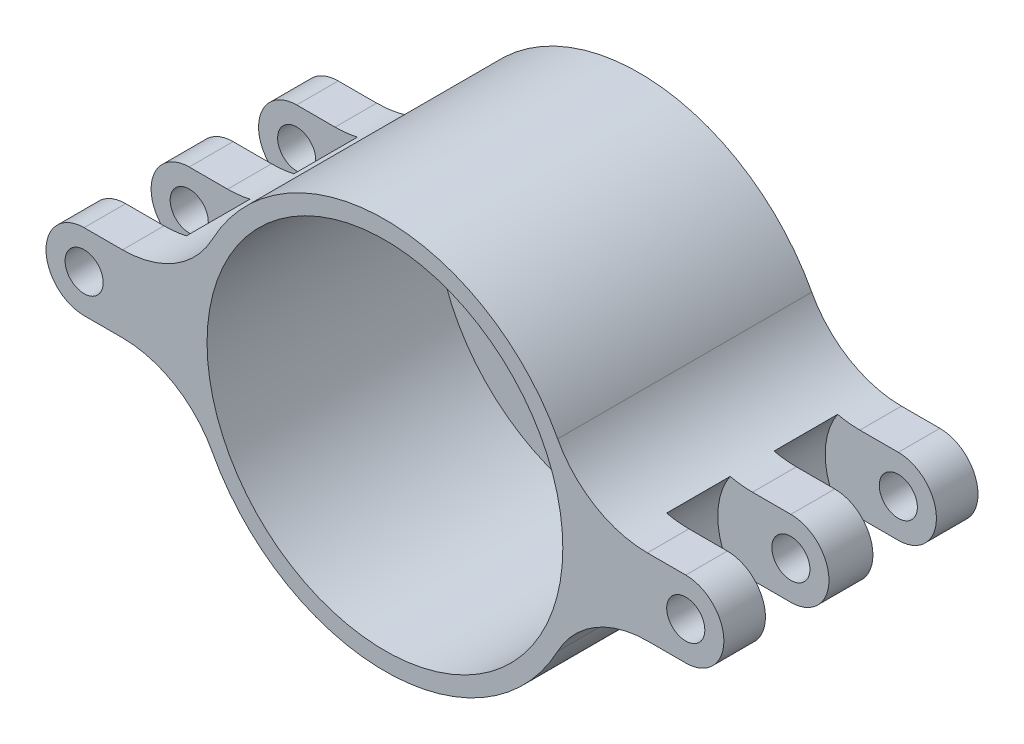
from build123d import *

# Parameters (mm, degrees)
SKETCH1_R                 = 15.4
BOSS_EXTRUDE1_DEPTH       = 20
BOSS_EXTRUDE2_DEPTH       = 20
FILLET4_R                 = 8
CIRPATTERN11_COUNT        = 2
FILLET4_OF_CIRPATTERN11_R = 8
SKETCH4_R                 = 14
CUT_EXTRUDE3_DEPTH        = 18
SKETCH5_R                 = 5
CUT_EXTRUDE4_DEPTH        = 19
CUT_EXTRUDE4_DEPTH_BACK   = 3
CUT_EXTRUDE5_START        = -3
SKETCH7_R                 = 3
CUT_EXTRUDE5_DEPTH        = 22
CIRPATTERN12_COUNT        = 4
CUT_EXTRUDE1_START        = -21
SKETCH2_R                 = 1.5
CUT_EXTRUDE1_DEPTH        = 22
CIRPATTERN10_COUNT        = 2
SKETCH3_R                 = 5.75
CUT_EXTRUDE2_DEPTH        = 2.5
CIRPATTERN3_COUNT         = 2
MIRROR1_COPY_1_SKETCH_R   = 5.75
MIRROR1_COPY_1_DEPTH      = 2.5


with BuildPart() as part:
    # Sketch1 → Boss-Extrude1 (new body)
    with BuildSketch(Plane.XY):
        Circle(SKETCH1_R)
    extrude(amount=BOSS_EXTRUDE1_DEPTH)

    # Sketch6 → Boss-Extrude2 (add)
    with BuildSketch(Plane.XY.offset(20)):
        with BuildLine():
            Line((-23.675, 3), (-15.104966071, 3))
            ThreePointArc((-15.104966071, 3), (-15.4, 0), (-15.104966071, -3))
            Line((-15.104966071, -3), (-23.675, -3))
            ThreePointArc((-23.675, -3), (-26.675, 0), (-23.675, 3))
        make_face()
    boss_extrude2 = extrude(amount=-BOSS_EXTRUDE2_DEPTH)

    # Fillet4
    fillet4_edges = [part.edges().sort_by_distance(p)[0] for p in [
        (-15.104966071, 3, 10),
        (-15.104966071, -3, 10),
    ]]
    fillet(fillet4_edges, radius=FILLET4_R)

    # CirPattern11: Boss-Extrude2 ×2 about axis
    cirpattern11_axis = Axis((0, 0, 0), (0, 0, 1))
    for i in range(1, CIRPATTERN11_COUNT):
        add(boss_extrude2.rotate(cirpattern11_axis, i * 360 / CIRPATTERN11_COUNT))

    # Fillet4 of CirPattern11
    fillet4_of_cirpattern11_edges = [part.edges().sort_by_distance(p)[0] for p in [
        (15.104966071, -3, 10),
        (15.104966071, 3, 10),
    ]]
    fillet(fillet4_of_cirpattern11_edges, radius=FILLET4_OF_CIRPATTERN11_R)

    # Sketch4 → Cut-Extrude3 (cut)
    with BuildSketch(Plane.XY.offset(20)):
        Circle(SKETCH4_R)
    extrude(amount=-CUT_EXTRUDE3_DEPTH, mode=Mode.SUBTRACT)

    # Sketch5 → Cut-Extrude4 (cut, two sides)
    with BuildSketch(Plane.XY.offset(2)) as cut_extrude4_sk:
        Circle(SKETCH5_R)
    extrude(amount=CUT_EXTRUDE4_DEPTH, mode=Mode.SUBTRACT)
    extrude(cut_extrude4_sk.sketch, amount=-CUT_EXTRUDE4_DEPTH_BACK, mode=Mode.SUBTRACT)

    # Sketch7 → Cut-Extrude5 (cut)
    with BuildSketch(Plane.XY.offset(2).offset(CUT_EXTRUDE5_START)):
        with Locations((-8.4, 0)):
            Circle(SKETCH7_R)
    cut_extrude5 = extrude(amount=CUT_EXTRUDE5_DEPTH, mode=Mode.SUBTRACT)

    # CirPattern12: Cut-Extrude5 ×4 about axis
    cirpattern12_axis = Axis((0, 0, 0), (0, 0, 1))
    for i in range(1, CIRPATTERN12_COUNT):
        add(cut_extrude5.rotate(cirpattern12_axis, i * 360 / CIRPATTERN12_COUNT), mode=Mode.SUBTRACT)

    # Sketch2 → Cut-Extrude1 (cut)
    with BuildSketch(Plane.XY.offset(20).offset(CUT_EXTRUDE1_START)):
        with Locations((-23.675, 0)):
            Circle(SKETCH2_R)
    cut_extrude1 = extrude(amount=CUT_EXTRUDE1_DEPTH, mode=Mode.SUBTRACT)

    # CirPattern10: Cut-Extrude1 ×2 about axis
    cirpattern10_axis = Axis((0, 0, 0), (0, 0, 1))
    for i in range(1, CIRPATTERN10_COUNT):
        add(cut_extrude1.rotate(cirpattern10_axis, i * 360 / CIRPATTERN10_COUNT), mode=Mode.SUBTRACT)

    # Sketch3 → Cut-Extrude2 (cut, symmetric)
    with BuildSketch(Plane.XY.offset(5.771567898)):
        with Locations((-23.675, 0)):
            Circle(SKETCH3_R)
    cut_extrude2 = extrude(amount=CUT_EXTRUDE2_DEPTH, both=True, mode=Mode.SUBTRACT)

    # CirPattern3: Cut-Extrude2 ×2 about axis
    cirpattern3_axis = Axis((0, 0, 0), (0, 0, 1))
    for i in range(1, CIRPATTERN3_COUNT):
        add(cut_extrude2.rotate(cirpattern3_axis, i * 360 / CIRPATTERN3_COUNT), mode=Mode.SUBTRACT)

    # Mirror1: Cut-Extrude2 across plane
    add(cut_extrude2.mirror(Plane.XY.offset(10)), mode=Mode.SUBTRACT)

    # Mirror1 copy 1 sketch → Mirror1 copy 1 (cut, symmetric)
    with BuildSketch(Plane(origin=(0, 0, 14.228432102), x_dir=(-1, 0, 0), z_dir=(0, 0, -1))):
        with Locations((-23.675, 0)):
            Circle(MIRROR1_COPY_1_SKETCH_R)
    extrude(amount=MIRROR1_COPY_1_DEPTH, both=True, mode=Mode.SUBTRACT)


solid = part.part
